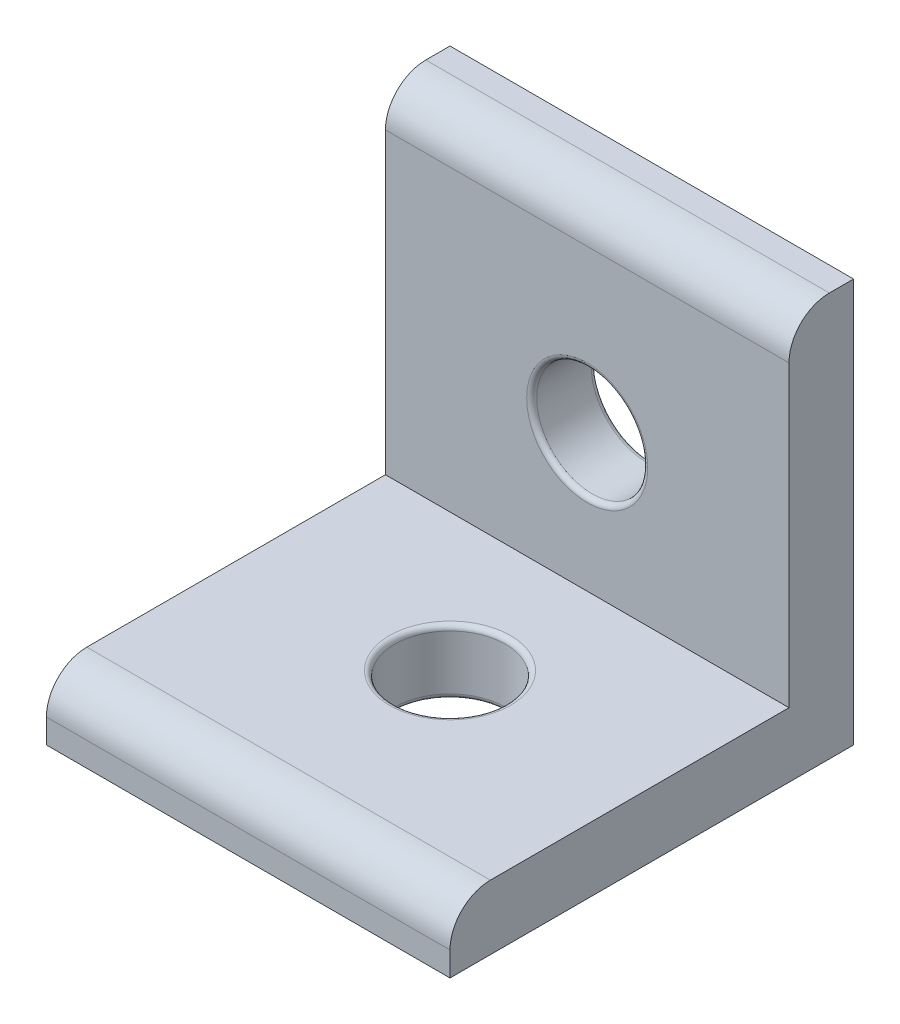
from build123d import *

# Parameters (mm, degrees)
SKETCH1_W           = 20
SKETCH1_H           = 20
BOSS_EXTRUDE1_DEPTH = 3.2
SKETCH2_W           = 20
SKETCH2_H           = 3.2
BOSS_EXTRUDE2_DEPTH = 16.8
SKETCH3_R           = 2.75
CUT_EXTRUDE1_DEPTH  = 4.2
SKETCH4_R           = 2.75
CUT_EXTRUDE2_DEPTH  = 4.2
FILLET1_R           = 2
FILLET2_R           = 0.25


with BuildPart() as part:
    # Sketch1 → Boss-Extrude1 (new body)
    with BuildSketch(Plane(origin=(0, 0, 0), x_dir=(1, 0, 0), z_dir=(0, 1, 0))):
        Rectangle(SKETCH1_W, SKETCH1_H)
    extrude(amount=BOSS_EXTRUDE1_DEPTH)

    # Sketch2 → Boss-Extrude2 (add)
    with BuildSketch(Plane(origin=(0, 3.2, 0), x_dir=(1, 0, 0), z_dir=(0, 1, 0))):
        with Locations((0, 8.4)):
            Rectangle(SKETCH2_W, SKETCH2_H)
    extrude(amount=BOSS_EXTRUDE2_DEPTH)

    # Sketch3 → Cut-Extrude1 (cut, through all)
    with BuildSketch(Plane(origin=(0, 3.2, 0), x_dir=(1, 0, 0), z_dir=(0, 1, 0))):
        Circle(SKETCH3_R)
    extrude(amount=-CUT_EXTRUDE1_DEPTH, mode=Mode.SUBTRACT)

    # Sketch4 → Cut-Extrude2 (cut, through all)
    with BuildSketch(Plane.XY.offset(-6.8)):
        with Locations((0, 10)):
            Circle(SKETCH4_R)
    extrude(amount=-CUT_EXTRUDE2_DEPTH, mode=Mode.SUBTRACT)

    # Fillet1
    fillet1_edges = [part.edges().sort_by_distance(p)[0] for p in [
        (0, 3.2, 10),
        (0, 20, -6.8),
    ]]
    fillet(fillet1_edges, radius=FILLET1_R)

    # Fillet2
    fillet2_edges = [part.edges().sort_by_distance(p)[0] for p in [
        (-2.75, 0, 0),
        (-2.75, 3.2, 0),
        (-2.75, 10, -10),
        (-2.75, 10, -6.8),
    ]]
    fillet(fillet2_edges, radius=FILLET2_R)


solid = part.part
